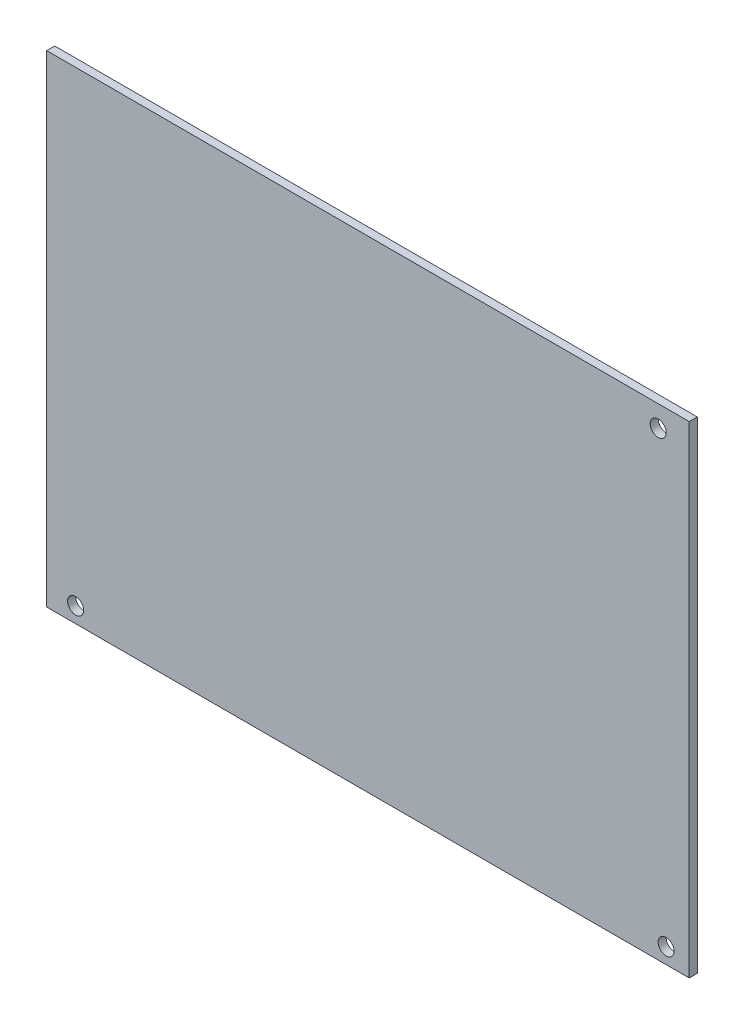
from build123d import *

# Parameters (mm, degrees)
SKETCH1_W           = 160
SKETCH1_H           = 120
BOSS_EXTRUDE1_DEPTH = 2
SKETCH2_R           = 2
CUT_EXTRUDE1_DEPTH  = 2


with BuildPart() as part:
    # Sketch1 → Boss-Extrude1 (new body)
    with BuildSketch(Plane.XY):
        with Locations((80, 60)):
            Rectangle(SKETCH1_W, SKETCH1_H)
    extrude(amount=BOSS_EXTRUDE1_DEPTH)

    # Sketch2 → Cut-Extrude1 (cut)
    with BuildSketch(Plane(origin=(0, 0, 0), x_dir=(-1, 0, 0), z_dir=(0, 0, -1))):
        with Locations((-7.194272825, 3.871446784)):
            Circle(SKETCH2_R)
        with Locations((-154.240322784, 3.871446784)):
            Circle(SKETCH2_R)
        with Locations((-152.267753821, 114.693957607)):
            Circle(SKETCH2_R)
    extrude(amount=-CUT_EXTRUDE1_DEPTH, mode=Mode.SUBTRACT)


solid = part.part
